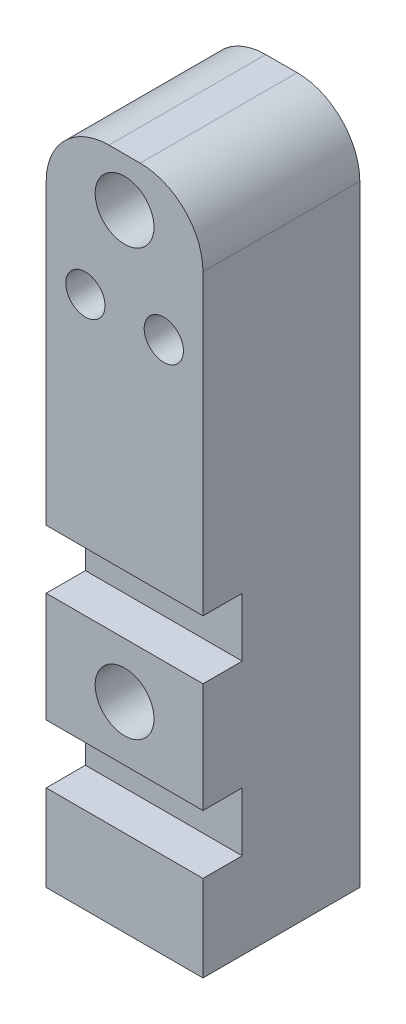
from build123d import *

# Parameters (mm, degrees)
SKETCH2_W           = 25.4
SKETCH2_H           = 109.22
BOSS_EXTRUDE1_DEPTH = 25.4
SKETCH3_R           = 4.7625
SKETCH3_R_2         = 3.175
CUT_EXTRUDE1_DEPTH  = 25.4
SKETCH4_W           = 25.4
SKETCH4_H           = 9.525
CUT_EXTRUDE2_DEPTH  = 6.35
SKETCH5_R           = 4.7625
CUT_EXTRUDE3_DEPTH  = 16.51
SKETCH6_R           = 2.54
CUT_EXTRUDE4_DEPTH  = 17.78
FILLET1_R           = 10.16


with BuildPart() as part:
    # Sketch2 → Boss-Extrude1 (new body)
    with BuildSketch(Plane.XY):
        Rectangle(SKETCH2_W, SKETCH2_H)
    extrude(amount=BOSS_EXTRUDE1_DEPTH)

    # Sketch3 → Cut-Extrude1 (cut)
    with BuildSketch(Plane.XY.offset(25.4)):
        with Locations((0, -22.225)):
            Circle(SKETCH3_R)
        with Locations((6.35, 31.75)):
            Circle(SKETCH3_R_2)
        with Locations((-6.35, 31.75)):
            Circle(SKETCH3_R_2)
    extrude(amount=-CUT_EXTRUDE1_DEPTH, mode=Mode.SUBTRACT)

    # Sketch4 → Cut-Extrude2 (cut)
    with BuildSketch(Plane.XY.offset(25.4)):
        with Locations((0, -8.5725)):
            Rectangle(SKETCH4_W, SKETCH4_H)
        with Locations((0, -35.8775)):
            Rectangle(SKETCH4_W, SKETCH4_H)
    extrude(amount=-CUT_EXTRUDE2_DEPTH, mode=Mode.SUBTRACT)

    # Sketch5 → Cut-Extrude3 (cut)
    with BuildSketch(Plane.XY.offset(25.4)):
        with Locations((0, 46.736)):
            Circle(SKETCH5_R)
    extrude(amount=-CUT_EXTRUDE3_DEPTH, mode=Mode.SUBTRACT)

    # Sketch6 → Cut-Extrude4 (cut)
    with BuildSketch(Plane.XZ.offset(54.61)):
        with Locations((0, 12.7)):
            Circle(SKETCH6_R)
    extrude(amount=-CUT_EXTRUDE4_DEPTH, mode=Mode.SUBTRACT)

    # Fillet1
    fillet1_edges = [part.edges().sort_by_distance(p)[0] for p in [
        (-12.7, 54.61, 12.7),
        (12.7, 54.61, 12.7),
    ]]
    fillet(fillet1_edges, radius=FILLET1_R)


solid = part.part
